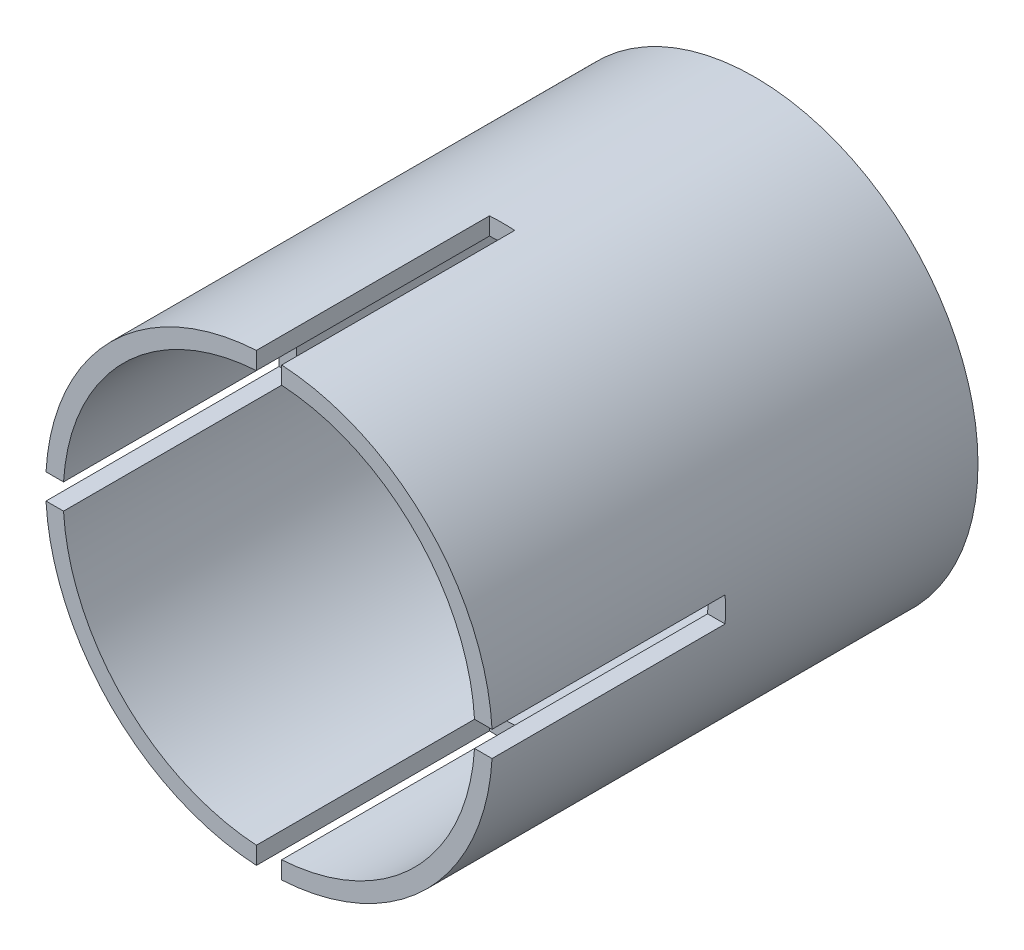
from build123d import *

# Parameters (mm, degrees)
SKETCH_1_R               = 11.5
SKETCH_1_R_2             = 10.6
EXTRUDE_1_DEPTH          = 25
SKETCH_2_R               = 11.5
EXTRUDE_2_DEPTH          = 1
SKETCH_3_W               = 3
SKETCH_3_H               = 1.3
CUT_EXTRUDE_4_DEPTH      = 12
PATTERN_CIRCULAR_1_COUNT = 4


with BuildPart() as part:
    # ｽｹｯﾁ1 → ﾎﾞｽ - 押し出し1 (new body)
    with BuildSketch(Plane.XY):
        Circle(SKETCH_1_R)
        Circle(SKETCH_1_R_2, mode=Mode.SUBTRACT)
    extrude(amount=EXTRUDE_1_DEPTH)

    # ｽｹｯﾁ2 → ﾎﾞｽ - 押し出し2 (add)
    with BuildSketch(Plane.XY):
        Circle(SKETCH_2_R)
    extrude(amount=EXTRUDE_2_DEPTH)

    # ｽｹｯﾁ3 → ｶｯﾄ - 押し出し4 (cut)
    with BuildSketch(Plane.XY.offset(25)):
        with Locations((11.5, 0)):
            Rectangle(SKETCH_3_W, SKETCH_3_H)
    cut_extrude_4 = extrude(amount=-CUT_EXTRUDE_4_DEPTH, mode=Mode.SUBTRACT)

    # 円形ﾊﾟﾀｰﾝ1: ｶｯﾄ - 押し出し4 ×4 about axis
    pattern_circular_1_axis = Axis((0, 0, 0), (0, 0, 1))
    for i in range(1, PATTERN_CIRCULAR_1_COUNT):
        add(cut_extrude_4.rotate(pattern_circular_1_axis, i * 360 / PATTERN_CIRCULAR_1_COUNT), mode=Mode.SUBTRACT)


solid = part.part
